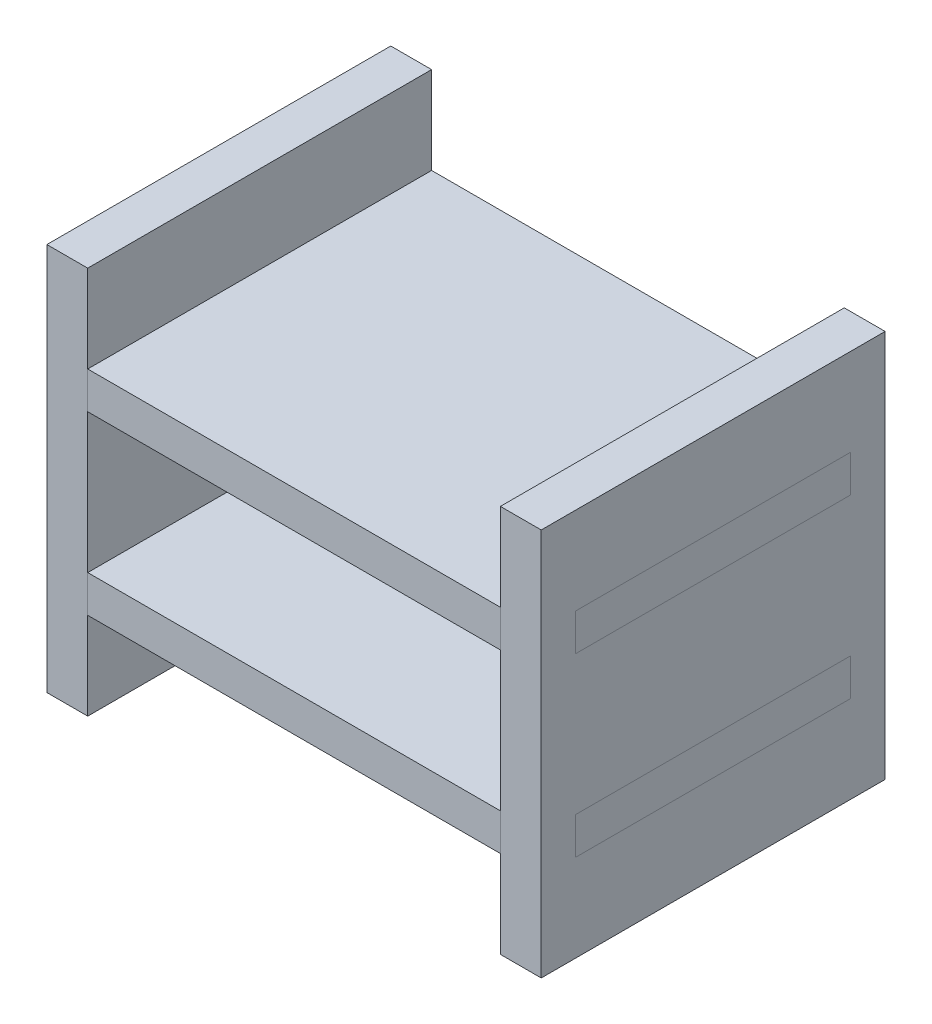
from build123d import *

# Parameters (mm, degrees)
SKETCH2_W           = 30
SKETCH2_H           = 25
SKETCH2_W_2         = 2.97
SKETCH2_H_2         = 20
BOSS_EXTRUDE3_DEPTH = 2.69
BOSS_EXTRUDE4_START = 12.81745
SKETCH2_3_W         = 2.97
SKETCH2_3_H         = 20
SKETCH2_3_W_2       = 30
SKETCH2_3_H_2       = 25
BOSS_EXTRUDE4_DEPTH = 2.69
SKETCH4_W           = 25
SKETCH4_H           = 28.20745
SKETCH4_W_2         = 20
SKETCH4_H_2         = 2.69
BOSS_EXTRUDE5_DEPTH = 2.97


with BuildPart() as part:
    # Sketch2 → Boss-Extrude3 (new body)
    with BuildSketch(Plane(origin=(0, 0, 0), x_dir=(1, 0, 0), z_dir=(0, 1, 0))):
        Rectangle(SKETCH2_W, SKETCH2_H)
        with Locations((-16.485, 0)):
            Rectangle(SKETCH2_W_2, SKETCH2_H_2)
        with Locations((16.485, 0)):
            Rectangle(SKETCH2_W_2, SKETCH2_H_2)
    extrude(amount=BOSS_EXTRUDE3_DEPTH)


with BuildPart() as body_2:
    # Sketch2_3 → Boss-Extrude4 (new body)
    with BuildSketch(Plane(origin=(0, 0, 0), x_dir=(1, 0, 0), z_dir=(0, 1, 0)).offset(BOSS_EXTRUDE4_START)):
        with Locations((-16.485, 0)):
            Rectangle(SKETCH2_3_W, SKETCH2_3_H)
        Rectangle(SKETCH2_3_W_2, SKETCH2_3_H_2)
        with Locations((16.485, 0)):
            Rectangle(SKETCH2_3_W, SKETCH2_3_H)
    extrude(amount=BOSS_EXTRUDE4_DEPTH)


with BuildPart() as body_3:
    # Sketch4 → Boss-Extrude5 (new body)
    with BuildSketch(Plane(origin=(15, 0, 0), x_dir=(0, 0, -1), z_dir=(1, 0, 0))):
        with Locations((0, 7.753725)):
            Rectangle(SKETCH4_W, SKETCH4_H)
        with Locations((0, 14.16245)):
            Rectangle(SKETCH4_W_2, SKETCH4_H_2, mode=Mode.SUBTRACT)
        with Locations((0, 1.345)):
            Rectangle(SKETCH4_W_2, SKETCH4_H_2, mode=Mode.SUBTRACT)
    extrude(amount=BOSS_EXTRUDE5_DEPTH)


with BuildPart() as body_4:
    # Mirror1: mirrored copy
    add(body_3.part.mirror(Plane(origin=(0, 0, 0), x_dir=(0, 0, 1), z_dir=(1, 0, 0))))


solid = Compound([part.part, body_2.part, body_3.part, body_4.part])
